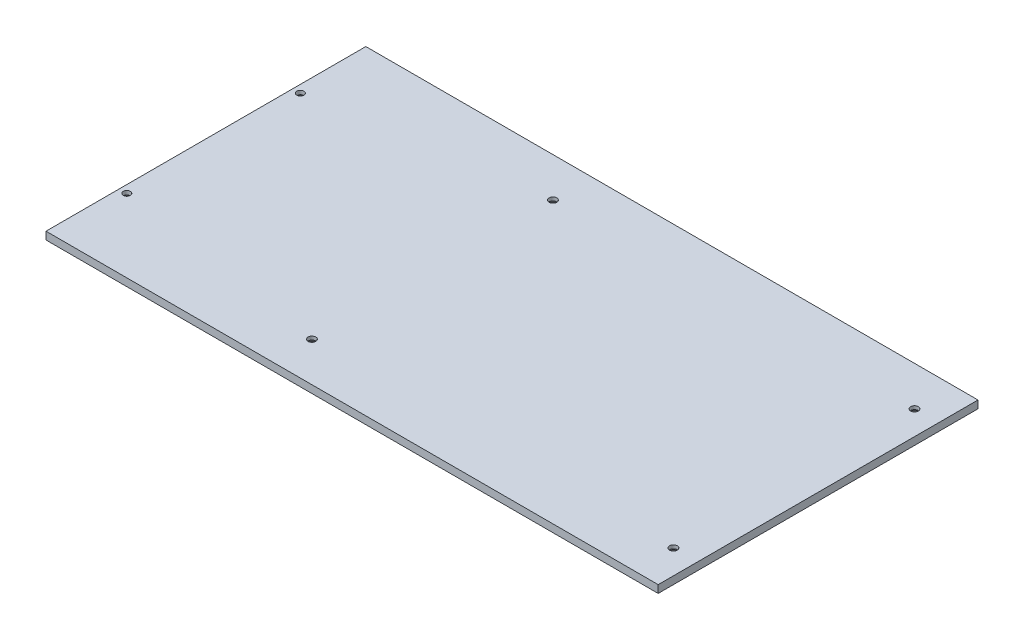
from build123d import *

# Parameters (mm, degrees)
SKETCH1_W                                      = 254
SKETCH1_H                                      = 132.70000003
BOSS_EXTRUDE1_DEPTH                            = 3.175
CSK_FOR_M3_SFHCS1_D                            = 3.2
CSK_FOR_M3_SFHCS1_DEPTH                        = 10.9728
CSK_FOR_M3_SFHCS1_CSINK_D                      = 6.72
CSK_FOR_M3_SFHCS1_CSINK_ANGLE                  = 90
CSK_FOR_M3_SFHCS1_TIP                          = 0.96137699
CSK_FOR_4_FLAT_HEAD_MACHINE_SCREW1_D           = 2.9464
CSK_FOR_4_FLAT_HEAD_MACHINE_SCREW1_DEPTH       = 10.9728
CSK_FOR_4_FLAT_HEAD_MACHINE_SCREW1_CSINK_D     = 5.715
CSK_FOR_4_FLAT_HEAD_MACHINE_SCREW1_CSINK_ANGLE = 82
CSK_FOR_4_FLAT_HEAD_MACHINE_SCREW1_TIP         = 0.885187864


with BuildPart() as part:
    # Sketch1 → Boss-Extrude1 (new body)
    with BuildSketch(Plane(origin=(0, 0, 0), x_dir=(1, 0, 0), z_dir=(0, 1, 0))):
        with Locations((127, 66.350000015)):
            Rectangle(SKETCH1_W, SKETCH1_H)
    extrude(amount=BOSS_EXTRUDE1_DEPTH)

    # CSK for M3 SFHCS1
    with Locations(Plane(origin=(0, 0, 0), x_dir=(-1, 0, 0), z_dir=(0, -1, 0))):
        with Locations((-244, 116.350000015), (-94, 116.350000015), (-94, 16.350000015), (-244, 16.350000015)):
            CounterSinkHole(CSK_FOR_M3_SFHCS1_D / 2, CSK_FOR_M3_SFHCS1_CSINK_D / 2, depth=CSK_FOR_M3_SFHCS1_DEPTH, counter_sink_angle=CSK_FOR_M3_SFHCS1_CSINK_ANGLE)
            with Locations((0, 0, -(CSK_FOR_M3_SFHCS1_DEPTH + CSK_FOR_M3_SFHCS1_TIP / 2))):  # 118° drill point
                Cone(0, CSK_FOR_M3_SFHCS1_D / 2, CSK_FOR_M3_SFHCS1_TIP, mode=Mode.SUBTRACT)

    # CSK for #4 Flat Head Machine Screw1
    with Locations(Plane(origin=(0, 0, 0), x_dir=(-1, 0, 0), z_dir=(0, -1, 0))):
        with Locations((-3.175, 102.350000024), (-3.175, 30.350000006)):
            CounterSinkHole(CSK_FOR_4_FLAT_HEAD_MACHINE_SCREW1_D / 2, CSK_FOR_4_FLAT_HEAD_MACHINE_SCREW1_CSINK_D / 2, depth=CSK_FOR_4_FLAT_HEAD_MACHINE_SCREW1_DEPTH, counter_sink_angle=CSK_FOR_4_FLAT_HEAD_MACHINE_SCREW1_CSINK_ANGLE)
            with Locations((0, 0, -(CSK_FOR_4_FLAT_HEAD_MACHINE_SCREW1_DEPTH + CSK_FOR_4_FLAT_HEAD_MACHINE_SCREW1_TIP / 2))):  # 118° drill point
                Cone(0, CSK_FOR_4_FLAT_HEAD_MACHINE_SCREW1_D / 2, CSK_FOR_4_FLAT_HEAD_MACHINE_SCREW1_TIP, mode=Mode.SUBTRACT)


solid = part.part
